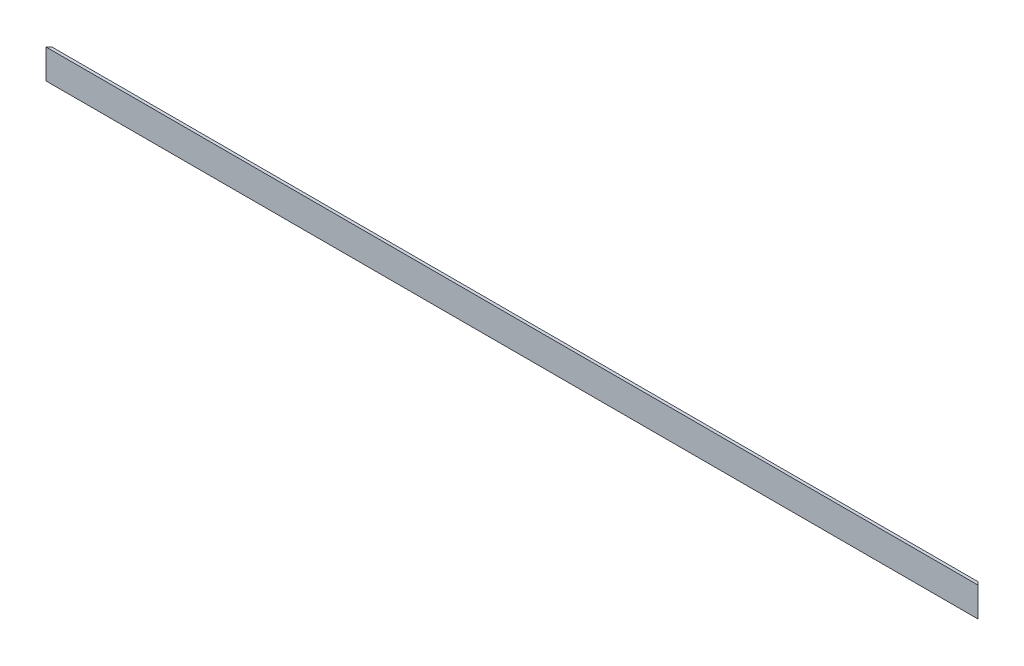
from build123d import *

# Parameters (mm, degrees)
EXTRUDE_1_DEPTH     = 475
CUT_EXTRUDE_1_DEPTH = 16


with BuildPart() as part:
    # Эскиз1 → Бобышка-Вытянуть1 (new body)
    with BuildSketch(Plane(origin=(0, 0, 0), x_dir=(0, 0, -1), z_dir=(1, 0, 0))):
        Polygon((0, 0), (0, 15), (1.5, 15), (1.5, 1.5), (15, 1.5), (15, 0), align=None)
    extrude(amount=EXTRUDE_1_DEPTH)

    # Эскиз2 → Вырез-Вытянуть1 (cut, through all)
    with BuildSketch(Plane.XZ):
        Polygon((475, 0), (454.951956964, -20.048043036), (475, -20.048043036), align=None)
    cut_extrude_1 = extrude(amount=-CUT_EXTRUDE_1_DEPTH, mode=Mode.SUBTRACT)

    # Зеркальное отражение1: Вырез-Вытянуть1 across plane
    add(cut_extrude_1.mirror(Plane(origin=(237.5, 0, 0), x_dir=(0, 0, 1), z_dir=(1, 0, 0))), mode=Mode.SUBTRACT)


solid = part.part
